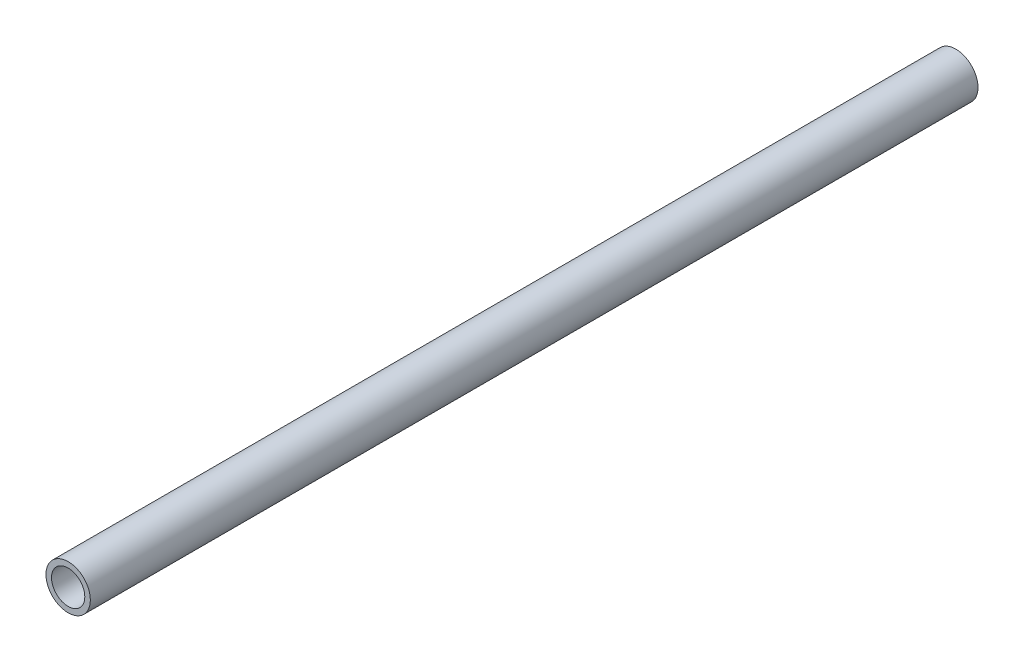
from build123d import *

# Parameters (mm, degrees)
ESQUISSE1_R        = 4
ESQUISSE1_R_2      = 3
BOSS_EXTRU_1_DEPTH = 160


with BuildPart() as part:
    # Esquisse1 → Boss.-Extru.1 (new body)
    with BuildSketch(Plane.XY):
        Circle(ESQUISSE1_R)
        Circle(ESQUISSE1_R_2, mode=Mode.SUBTRACT)
    extrude(amount=BOSS_EXTRU_1_DEPTH)


solid = part.part
